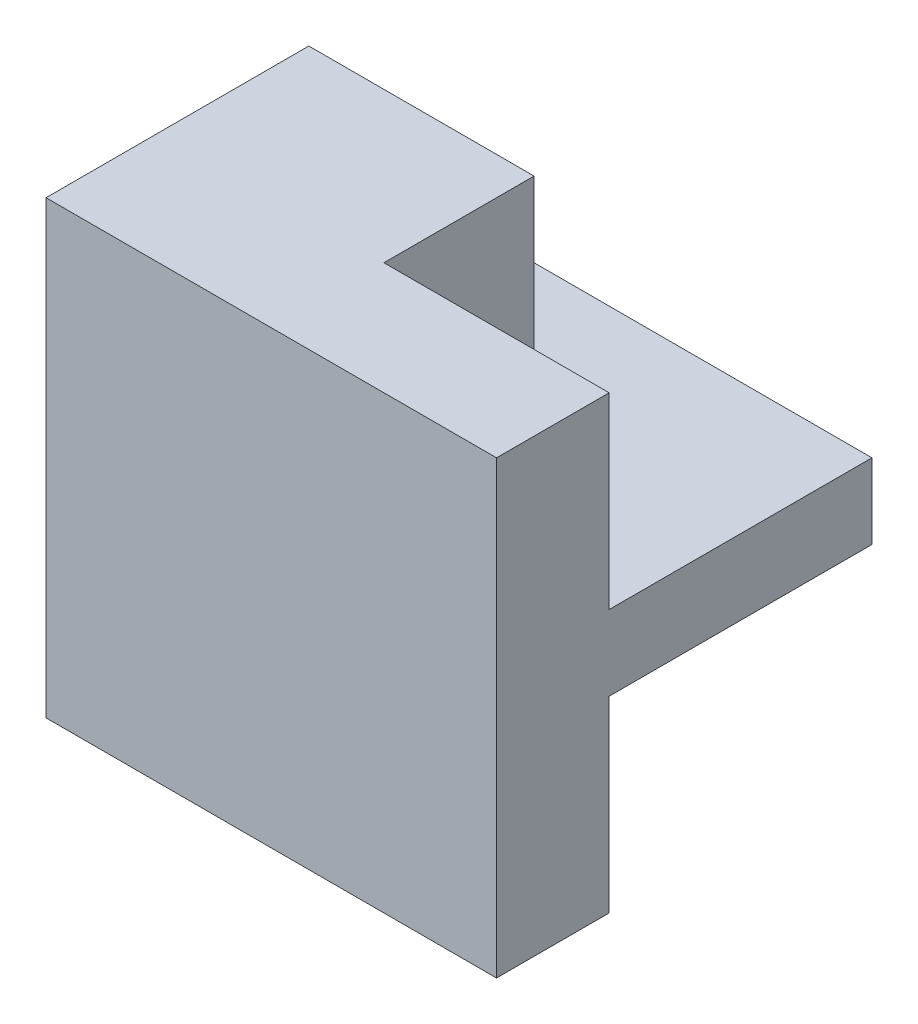
from build123d import *

# Parameters (mm, degrees)
SKETCH1_W           = 6
SKETCH1_H           = 5
BOSS_EXTRUDE1_DEPTH = 6
CUT_EXTRUDE1_DEPTH  = 2.5
CUT_EXTRUDE2_DEPTH  = 2.5


with BuildPart() as part:
    # Sketch1 → Boss-Extrude1 (new body)
    with BuildSketch(Plane(origin=(0, 0, 0), x_dir=(1, 0, 0), z_dir=(0, 1, 0))):
        Rectangle(SKETCH1_W, SKETCH1_H)
    extrude(amount=BOSS_EXTRUDE1_DEPTH)

    # Sketch2 → Cut-Extrude1 (cut)
    with BuildSketch(Plane(origin=(0, 6, 0), x_dir=(1, 0, 0), z_dir=(0, 1, 0))):
        Polygon((0, -1), (3, -1), (3, 2.5), (-3, 2.5), (-3, 1), (0, 1), align=None)
    extrude(amount=-CUT_EXTRUDE1_DEPTH, mode=Mode.SUBTRACT)

    # Sketch3 → Cut-Extrude2 (cut)
    with BuildSketch(Plane.XZ):
        Polygon((3, -2.5), (3, 1), (0, 1), (0, -1), (-3, -1), (-3, -2.5), align=None)
    extrude(amount=-CUT_EXTRUDE2_DEPTH, mode=Mode.SUBTRACT)


solid = part.part
